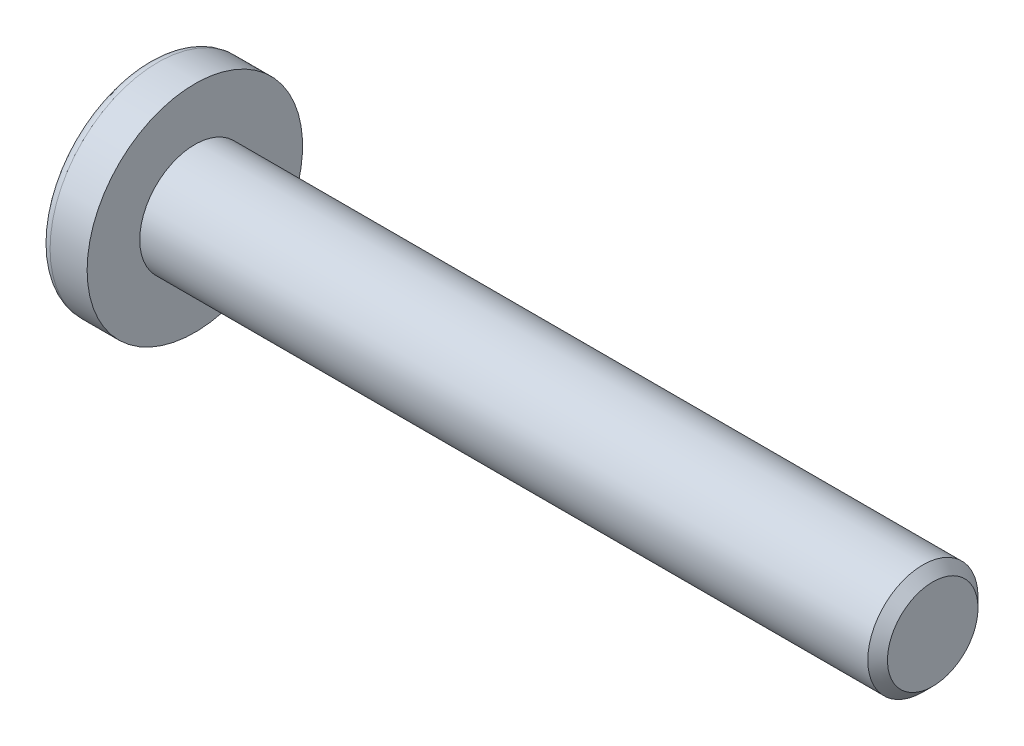
from build123d import *

# Parameters (mm, degrees)
SKETCH3_W         = 0.8128
SKETCH3_H         = 3.6322
SKETCH4_W         = 0.4064
SKETCH4_H         = 0.4064
CIRPATTERN1_COUNT = 2
CIRPATTERN1_ANGLE = 90
CHAMFER1_SIZE     = 0.254


with BuildPart() as part:
    # BodySke → Base-Revolve (revolve)
    with BuildSketch(Plane.XY, mode=Mode.PRIVATE) as base_revolve_sk:
        with BuildLine():
            Line((2.032, 1.4224), (2.032, 2.7813))
            Line((2.032, 2.7813), (1.075646615, 2.7813))
            ThreePointArc((1.075646615, 2.7813), (0.960371669, 2.753635341), (0.87020729, 2.676667612))
            ThreePointArc((0.87020729, 2.676667612), (0.223015279, 1.407285528), (0, 0))
            Line((0, 0), (21.082, 0))
            Line((21.082, 0), (21.082, 1.4224))
            Line((21.082, 1.4224), (2.032, 1.4224))
        make_face()
    revolve(base_revolve_sk.sketch.rotate(Axis((-25.4, 0, 0), (1, 0, 0)), 90), axis=Axis((-25.4, 0, 0), (1, 0, 0)))  # turned: the seam where the file's is

    # Sketch3 → Cut-Loft1 section 0
    with BuildSketch(Plane(origin=(0, 0, 0), x_dir=(0, 0, -1), z_dir=(1, 0, 0))):
        Rectangle(SKETCH3_W, SKETCH3_H)
    # Sketch4 → Cut-Loft1 section 1
    with BuildSketch(Plane(origin=(2.0066, 0, 0), x_dir=(0, 0, -1), z_dir=(1, 0, 0))):
        Rectangle(SKETCH4_W, SKETCH4_H)
    cut_loft1 = loft(mode=Mode.SUBTRACT)

    # CirPattern1: Cut-Loft1 ×2 about axis
    cirpattern1_axis = Axis((0, 0, 0), (1, 0, 0))
    for i in range(1, CIRPATTERN1_COUNT):
        add(cut_loft1.rotate(cirpattern1_axis, i * CIRPATTERN1_ANGLE / (CIRPATTERN1_COUNT - 1)), mode=Mode.SUBTRACT)

    # Chamfer1
    chamfer1_edges = [part.edges().sort_by_distance(p)[0] for p in [
        (21.082, 0, -1.4224),
    ]]
    chamfer(chamfer1_edges, length=CHAMFER1_SIZE)


solid = part.part
